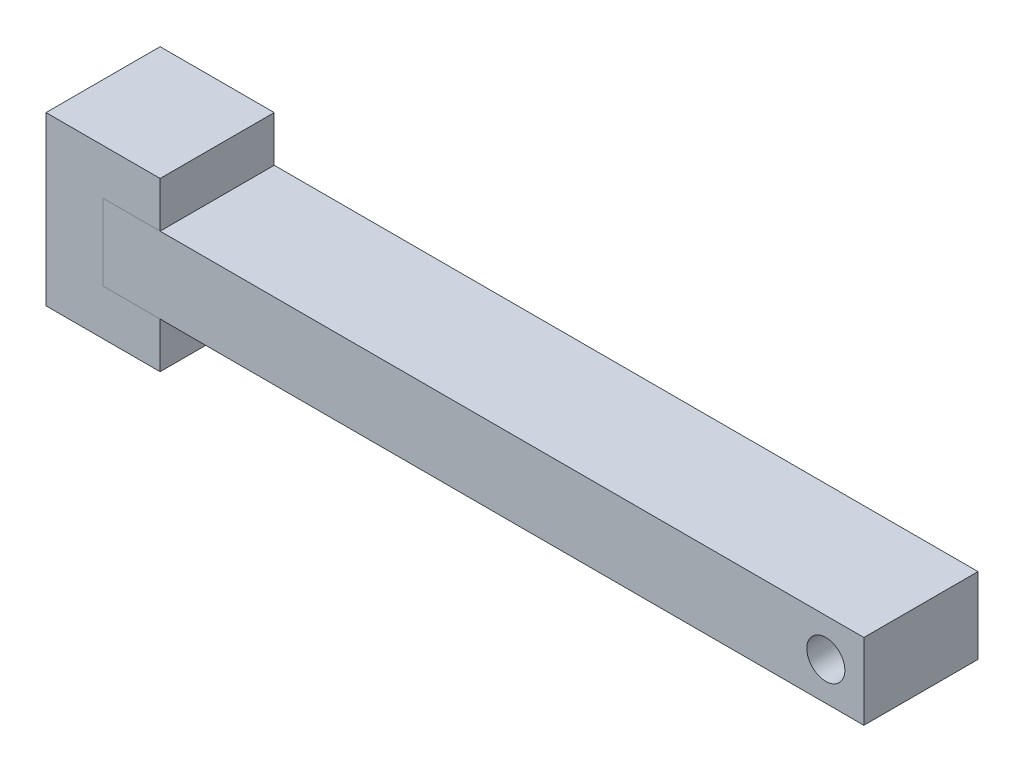
from build123d import *

# Parameters (mm, degrees)
SKETCH1_W           = 1000
SKETCH1_H           = 150
BOSS_EXTRUDE1_DEPTH = 50
SKETCH2_R           = 25
CUT_EXTRUDE1_DEPTH  = 151
SKETCH4_W           = 150
SKETCH4_H           = 220
BOSS_EXTRUDE3_DEPTH = 150


with BuildPart() as part:
    # Sketch1 → Boss-Extrude1 (new body, symmetric)
    with BuildSketch(Plane(origin=(0, 0, 0), x_dir=(1, 0, 0), z_dir=(0, 1, 0))):
        Rectangle(SKETCH1_W, SKETCH1_H)
    extrude(amount=BOSS_EXTRUDE1_DEPTH, both=True)

    # Sketch2 → Cut-Extrude1 (cut, through all)
    with BuildSketch(Plane.XY.offset(75)):
        with Locations((450, 0)):
            Circle(SKETCH2_R)
    extrude(amount=-CUT_EXTRUDE1_DEPTH, mode=Mode.SUBTRACT)


with BuildPart() as body_2:
    # Sketch4 → Boss-Extrude3 (new body)
    with BuildSketch(Plane(origin=(0, 0, -75), x_dir=(-1, 0, 0), z_dir=(0, 0, -1))):
        with Locations((500, 0)):
            Rectangle(SKETCH4_W, SKETCH4_H)
    extrude(amount=-BOSS_EXTRUDE3_DEPTH)


solid = Compound([part.part, body_2.part])
